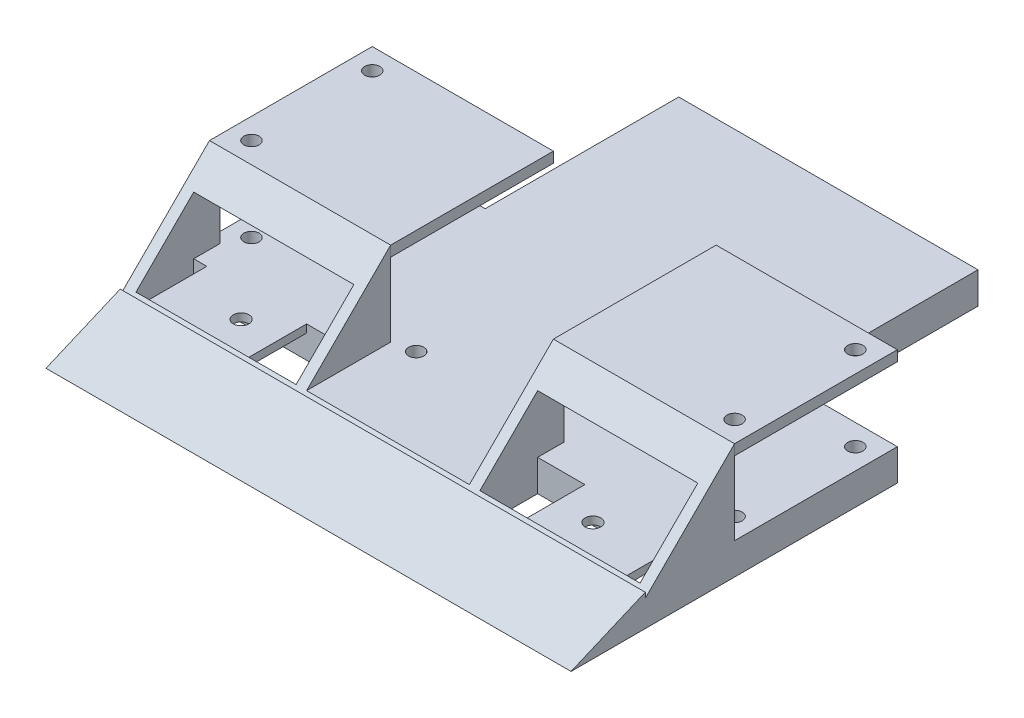
from build123d import *

# Parameters (mm, degrees)
SKETCH1_W             = 100
SKETCH1_H             = 100
BOSS_EXTRUDE1_DEPTH   = 6
CUT_EXTRUDE1_DEPTH    = 101
CUT_EXTRUDE3_DEPTH    = 101
SKETCH4_W             = 100
SKETCH4_H             = 1
CUT_EXTRUDE4_DEPTH    = 7
BOSS_EXTRUDE2_DEPTH   = 100
SKETCH8_W             = 34.5
SKETCH8_H             = 2
BOSS_EXTRUDE3_DEPTH   = 31
BOSS_EXTRUDE3_2_DEPTH = 31
SKETCH15_W            = 21.5
SKETCH15_H            = 36.86
CUT_EXTRUDE7_DEPTH    = 7
SKETCH18_W            = 31
SKETCH18_H            = 16
CUT_EXTRUDE8_DEPTH    = 48
SKETCH19_R            = 1.45
CUT_EXTRUDE9_DEPTH    = 23
SKETCH20_R            = 1.45
CUT_EXTRUDE10_DEPTH   = 7
SKETCH23_W            = 30.5
SKETCH23_H            = 11
CUT_EXTRUDE11_DEPTH   = 32.135114195
SKETCH27_W            = 30.5
SKETCH27_H            = 11
CUT_EXTRUDE14_DEPTH   = 10
SKETCH32_W            = 19
SKETCH32_H            = 1.5
BOSS_EXTRUDE6_DEPTH   = 11
SKETCH33_R            = 1.5
CUT_EXTRUDE15_DEPTH   = 6


with BuildPart() as part:
    # Sketch1 → Boss-Extrude1 (new body)
    with BuildSketch(Plane(origin=(0, 0, 0), x_dir=(1, 0, 0), z_dir=(0, 1, 0))):
        Rectangle(SKETCH1_W, SKETCH1_H)
    extrude(amount=BOSS_EXTRUDE1_DEPTH)

    # Sketch2 → Cut-Extrude1 (cut, through all)
    with BuildSketch(Plane(origin=(50, 0, 0), x_dir=(0, 0, -1), z_dir=(1, 0, 0))):
        Polygon((-50, 0), (-35.864885805, 6), (-50, 6), align=None)
    extrude(amount=-CUT_EXTRUDE1_DEPTH, mode=Mode.SUBTRACT)

    # Sketch3 → Cut-Extrude3 (cut, through all)
    with BuildSketch(Plane(origin=(50, 0, 0), x_dir=(0, 0, -1), z_dir=(1, 0, 0))):
        Polygon((-35.864885805, 6), (-35.864885805, 5), (-34.864885805, 6), align=None)
    extrude(amount=-CUT_EXTRUDE3_DEPTH, mode=Mode.SUBTRACT)

    # Sketch4 → Cut-Extrude4 (cut, through all)
    with BuildSketch(Plane(origin=(0, 6, 0), x_dir=(1, 0, 0), z_dir=(0, 1, 0))):
        with Locations((0, 49.5)):
            Rectangle(SKETCH4_W, SKETCH4_H)
    extrude(amount=-CUT_EXTRUDE4_DEPTH, mode=Mode.SUBTRACT)

    # Sketch6 → Boss-Extrude2 (add, through all)
    with BuildSketch(Plane(origin=(50, 0, 0), x_dir=(0, 0, -1), z_dir=(1, 0, 0))):
        Polygon((-34.864885805, 6), (-18.864885805, 22), (-18.864885805, 6), align=None)
    extrude(amount=-BOSS_EXTRUDE2_DEPTH)

    # Sketch15 → Cut-Extrude7 (cut, through all)
    with BuildSketch(Plane(origin=(0, 6, 0), x_dir=(1, 0, 0), z_dir=(0, 1, 0))):
        with Locations((-39.25, 30.57)):
            Rectangle(SKETCH15_W, SKETCH15_H)
        with Locations((39.25, 30.57)):
            Rectangle(SKETCH15_W, SKETCH15_H)
    extrude(amount=-CUT_EXTRUDE7_DEPTH, mode=Mode.SUBTRACT)

    # Sketch18 → Cut-Extrude8 (cut)
    with BuildSketch(Plane(origin=(0, 0, 18.864885805), x_dir=(-1, 0, 0), z_dir=(0, 0, -1))):
        with Locations((0, 14)):
            Rectangle(SKETCH18_W, SKETCH18_H)
    extrude(amount=-CUT_EXTRUDE8_DEPTH, mode=Mode.SUBTRACT)


with BuildPart() as body_2:
    # Sketch8 → Boss-Extrude3 (new body)
    with BuildSketch(Plane(origin=(0, 0, 18.864885805), x_dir=(-1, 0, 0), z_dir=(0, 0, -1))):
        with Locations((-32.75, 21)):
            Rectangle(SKETCH8_W, SKETCH8_H)
    extrude(amount=BOSS_EXTRUDE3_DEPTH)


with BuildPart() as body_3:
    # Sketch8 → Boss-Extrude3 2 (new body)
    with BuildSketch(Plane(origin=(0, 0, 18.864885805), x_dir=(-1, 0, 0), z_dir=(0, 0, -1))):
        with Locations((32.75, 21)):
            Rectangle(SKETCH8_W, SKETCH8_H)
    extrude(amount=BOSS_EXTRUDE3_2_DEPTH)


with BuildPart() as cut_extrude9_tool:
    # Sketch19 → Cut-Extrude9 (new body, through all)
    with BuildSketch(Plane(origin=(0, 22, 0), x_dir=(1, 0, 0), z_dir=(0, 1, 0))):
        with Locations((-46, -14.864885805)):
            Circle(SKETCH19_R)
        with Locations((-46, 8.135114195)):
            Circle(SKETCH19_R)
        with Locations((46, 8.135114195)):
            Circle(SKETCH19_R)
        with Locations((46, -14.864885805)):
            Circle(SKETCH19_R)
    extrude(amount=-CUT_EXTRUDE9_DEPTH)


with BuildPart() as part_1:
    add(part.part)

    # Cut-Extrude9: cut by cut_extrude9_tool
    add(cut_extrude9_tool.part, mode=Mode.SUBTRACT)

    # Sketch20 → Cut-Extrude10 (cut, through all)
    with BuildSketch(Plane(origin=(0, 6, 0), x_dir=(1, 0, 0), z_dir=(0, 1, 0))):
        with Locations((-11.5, -17.994885805)):
            Circle(SKETCH20_R)
        with Locations((11.5, -17.994885805)):
            Circle(SKETCH20_R)
    extrude(amount=-CUT_EXTRUDE10_DEPTH, mode=Mode.SUBTRACT)

    # Sketch23 → Cut-Extrude11 (cut, through all)
    with BuildSketch(Plane(origin=(0, 0, 18.864885805), x_dir=(-1, 0, 0), z_dir=(0, 0, -1))):
        with Locations((-32.75, 11.5)):
            Rectangle(SKETCH23_W, SKETCH23_H)
        with Locations((32.75, 11.5)):
            Rectangle(SKETCH23_W, SKETCH23_H)
    extrude(amount=-CUT_EXTRUDE11_DEPTH, mode=Mode.SUBTRACT)

    # Sketch27 → Cut-Extrude14 (cut)
    with BuildSketch(Plane.XZ):
        with Locations((-32.75, 29.364885805)):
            Rectangle(SKETCH27_W, SKETCH27_H)
        with Locations((32.75, 29.364885805)):
            Rectangle(SKETCH27_W, SKETCH27_H)
    extrude(amount=-CUT_EXTRUDE14_DEPTH, mode=Mode.SUBTRACT)

    # Sketch32 → Boss-Extrude6 (add)
    with BuildSketch(Plane.XY.offset(23.864885805)):
        with Locations((-36, 5.25)):
            Rectangle(SKETCH32_W, SKETCH32_H)
        with Locations((36, 5.25)):
            Rectangle(SKETCH32_W, SKETCH32_H)
    extrude(amount=BOSS_EXTRUDE6_DEPTH)

    # Sketch33 → Cut-Extrude15 (cut)
    with BuildSketch(Plane.XZ):
        with Locations((-33.5, 29.340498756)):
            Circle(SKETCH33_R)
        with Locations((33.5, 29.340498756)):
            Circle(SKETCH33_R)
    extrude(amount=-CUT_EXTRUDE15_DEPTH, mode=Mode.SUBTRACT)


with BuildPart() as body_2_1:
    add(body_2.part)

    # Cut-Extrude9: cut by cut_extrude9_tool
    add(cut_extrude9_tool.part, mode=Mode.SUBTRACT)


with BuildPart() as body_3_1:
    add(body_3.part)

    # Cut-Extrude9: cut by cut_extrude9_tool
    add(cut_extrude9_tool.part, mode=Mode.SUBTRACT)


solid = Compound([part_1.part, body_2_1.part, body_3_1.part])
